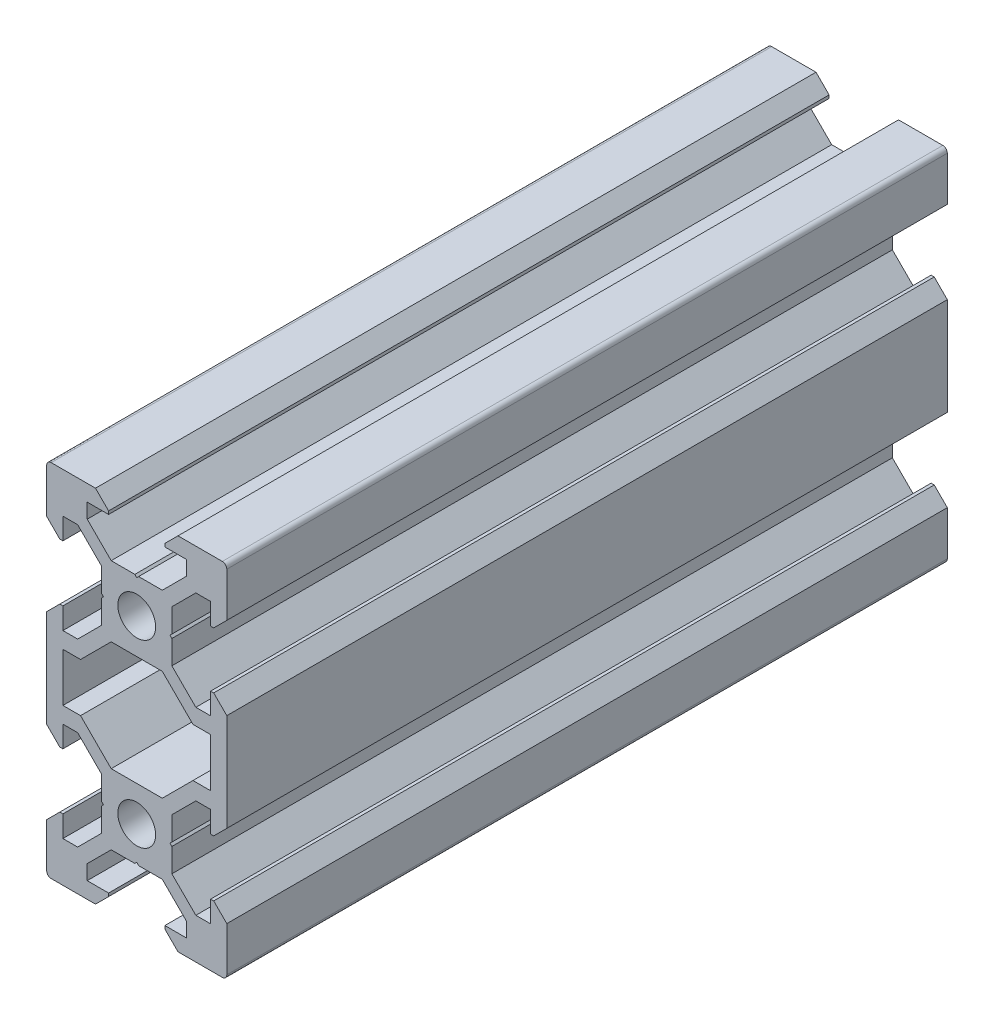
from build123d import *

# Parameters (mm, degrees)
SKETCH1_R           = 2.1
BOSS_EXTRUDE1_DEPTH = 80


with BuildPart() as part:
    # Sketch1 → Boss-Extrude1 (new body)
    with BuildSketch(Plane.XY):
        with BuildLine():
            Line((4.58, -20), (9.5, -20))
            ThreePointArc((9.5, -20), (9.853553391, -19.853553391), (10, -19.5))
            Line((10, -19.5), (10, -14.58))
            Line((10, -14.58), (8.545, -13.125))
            Line((8.545, -13.125), (8.2, -13.125))
            Line((8.2, -13.125), (8.2, -15.5))
            Line((8.2, -15.5), (6.560660172, -15.5))
            Line((6.560660172, -15.5), (3.9, -12.839339828))
            Line((3.9, -12.839339828), (3.9, -10.21))
            Line((3.9, -10.21), (3.69, -10))
            Line((3.69, -10), (3.9, -9.79))
            Line((3.9, -9.79), (3.9, -7.160660172))
            Line((3.9, -7.160660172), (6.560660172, -4.5))
            Line((6.560660172, -4.5), (8.2, -4.5))
            Line((8.2, -4.5), (8.2, -6.875))
            Line((8.2, -6.875), (8.545, -6.875))
            Line((8.545, -6.875), (10, -5.42))
            Line((10, -5.42), (10, 5.42))
            Line((10, 5.42), (8.545, 6.875))
            Line((8.545, 6.875), (8.2, 6.875))
            Line((8.2, 6.875), (8.2, 4.5))
            Line((8.2, 4.5), (6.560660172, 4.5))
            Line((6.560660172, 4.5), (3.9, 7.160660172))
            Line((3.9, 7.160660172), (3.9, 9.79))
            Line((3.9, 9.79), (3.69, 10))
            Line((3.69, 10), (3.9, 10.21))
            Line((3.9, 10.21), (3.9, 12.839339828))
            Line((3.9, 12.839339828), (6.560660172, 15.5))
            Line((6.560660172, 15.5), (8.2, 15.5))
            Line((8.2, 15.5), (8.2, 13.125))
            Line((8.2, 13.125), (8.545, 13.125))
            Line((8.545, 13.125), (10, 14.58))
            Line((10, 14.58), (10, 19.5))
            ThreePointArc((10, 19.5), (9.853553391, 19.853553391), (9.5, 20))
            Line((9.5, 20), (4.58, 20))
            Line((4.58, 20), (3.125, 18.545))
            Line((3.125, 18.545), (3.125, 18.2))
            Line((3.125, 18.2), (5.5, 18.2))
            Line((5.5, 18.2), (5.5, 16.560660172))
            Line((5.5, 16.560660172), (2.839339828, 13.9))
            Line((2.839339828, 13.9), (0.21, 13.9))
            Line((0.21, 13.9), (0, 13.69))
            Line((0, 13.69), (-0.21, 13.9))
            Line((-0.21, 13.9), (-2.839339828, 13.9))
            Line((-2.839339828, 13.9), (-5.5, 16.560660172))
            Line((-5.5, 16.560660172), (-5.5, 18.2))
            Line((-5.5, 18.2), (-3.125, 18.2))
            Line((-3.125, 18.2), (-3.125, 18.545))
            Line((-3.125, 18.545), (-4.58, 20))
            Line((-4.58, 20), (-9.5, 20))
            ThreePointArc((-9.5, 20), (-9.853553391, 19.853553391), (-10, 19.5))
            Line((-10, 19.5), (-10, 14.58))
            Line((-10, 14.58), (-8.545, 13.125))
            Line((-8.545, 13.125), (-8.2, 13.125))
            Line((-8.2, 13.125), (-8.2, 15.5))
            Line((-8.2, 15.5), (-6.560660172, 15.5))
            Line((-6.560660172, 15.5), (-3.9, 12.839339828))
            Line((-3.9, 12.839339828), (-3.9, 10.21))
            Line((-3.9, 10.21), (-3.69, 10))
            Line((-3.69, 10), (-3.9, 9.79))
            Line((-3.9, 9.79), (-3.9, 7.160660172))
            Line((-3.9, 7.160660172), (-6.560660172, 4.5))
            Line((-6.560660172, 4.5), (-8.2, 4.5))
            Line((-8.2, 4.5), (-8.2, 6.875))
            Line((-8.2, 6.875), (-8.545, 6.875))
            Line((-8.545, 6.875), (-10, 5.42))
            Line((-10, 5.42), (-10, -5.42))
            Line((-10, -5.42), (-8.545, -6.875))
            Line((-8.545, -6.875), (-8.2, -6.875))
            Line((-8.2, -6.875), (-8.2, -4.5))
            Line((-8.2, -4.5), (-6.560660172, -4.5))
            Line((-6.560660172, -4.5), (-3.9, -7.160660172))
            Line((-3.9, -7.160660172), (-3.9, -9.79))
            Line((-3.9, -9.79), (-3.69, -10))
            Line((-3.69, -10), (-3.9, -10.21))
            Line((-3.9, -10.21), (-3.9, -12.839339828))
            Line((-3.9, -12.839339828), (-6.560660172, -15.5))
            Line((-6.560660172, -15.5), (-8.2, -15.5))
            Line((-8.2, -15.5), (-8.2, -13.125))
            Line((-8.2, -13.125), (-8.545, -13.125))
            Line((-8.545, -13.125), (-10, -14.58))
            Line((-10, -14.58), (-10, -19.5))
            ThreePointArc((-10, -19.5), (-9.853553391, -19.853553391), (-9.5, -20))
            Line((-9.5, -20), (-4.58, -20))
            Line((-4.58, -20), (-3.125, -18.545))
            Line((-3.125, -18.545), (-3.125, -18.2))
            Line((-3.125, -18.2), (-5.5, -18.2))
            Line((-5.5, -18.2), (-5.5, -16.560660172))
            Line((-5.5, -16.560660172), (-2.839339828, -13.9))
            Line((-2.839339828, -13.9), (-0.21, -13.9))
            Line((-0.21, -13.9), (0, -13.69))
            Line((0, -13.69), (0.21, -13.9))
            Line((0.21, -13.9), (2.839339828, -13.9))
            Line((2.839339828, -13.9), (5.5, -16.560660172))
            Line((5.5, -16.560660172), (5.5, -18.2))
            Line((5.5, -18.2), (3.125, -18.2))
            Line((3.125, -18.2), (3.125, -18.545))
            Line((3.125, -18.545), (4.58, -20))
        make_face()
        with Locations((0, -10)):
            Circle(SKETCH1_R, mode=Mode.SUBTRACT)
        Polygon((-6.239339828, -2.7), (-8.2, -2.7), (-8.2, 2.7), (-6.239339828, 2.7), (-2.839339828, 6.1), (2.839339828, 6.1), (6.239339828, 2.7), (8.2, 2.7), (8.2, -2.7), (6.239339828, -2.7), (2.839339828, -6.1), (-2.839339828, -6.1), align=None, mode=Mode.SUBTRACT)
        with Locations((0, 10)):
            Circle(SKETCH1_R, mode=Mode.SUBTRACT)
    extrude(amount=BOSS_EXTRUDE1_DEPTH)


solid = part.part
